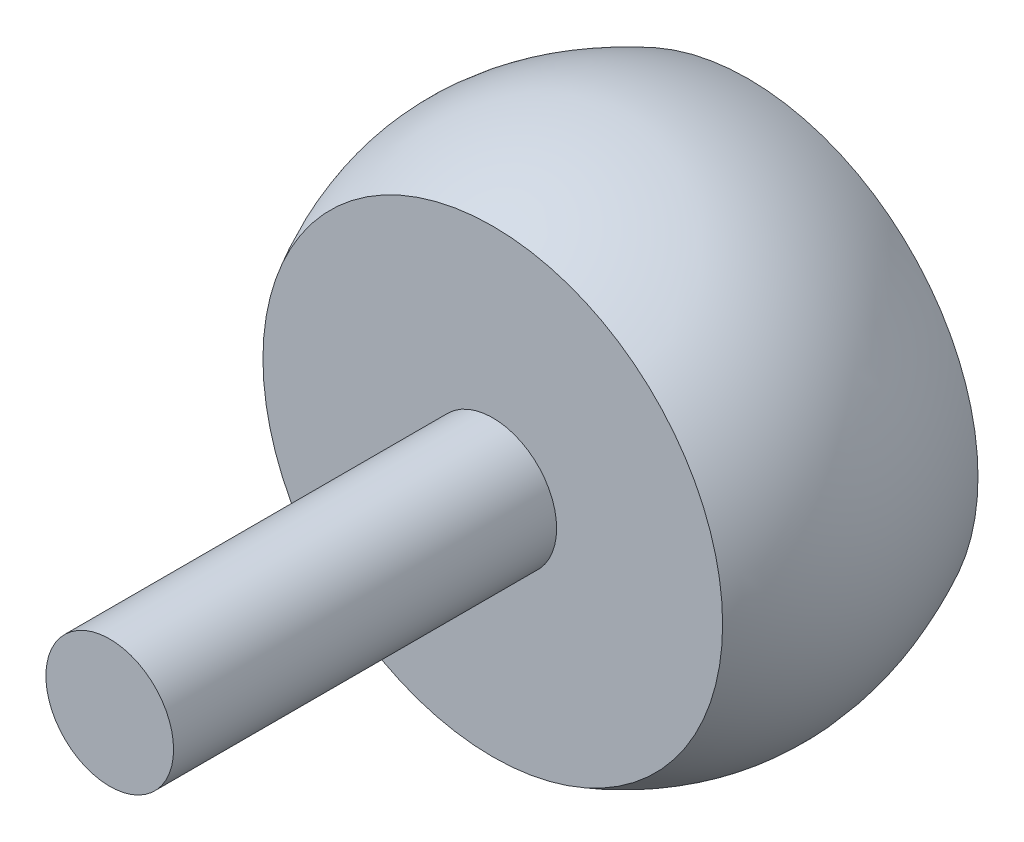
from build123d import *

# Parameters (mm, degrees)
SKETCH1_R           = 9
BOSS_EXTRUDE1_DEPTH = 10
SKETCH3_R           = 2.5
BOSS_EXTRUDE2_DEPTH = 15


with BuildPart() as part:
    # Sketch1 → Boss-Extrude1 (new body)
    with BuildSketch(Plane.XY):
        Circle(SKETCH1_R)
    extrude(amount=BOSS_EXTRUDE1_DEPTH)

    # Sketch2 → Revolve1 (revolve)
    with BuildSketch(Plane(origin=(0, 0, 0), x_dir=(0, 0, -1), z_dir=(1, 0, 0))):
        with BuildLine():
            Line((-10, 9), (0, 9))
            add(Edge.make_bspline(
                [(-10, 9), (-7.025299732, 10.664982645), (-3.75093179, 10.87766674), (0, 9)],
                knots=[0, 0, 0, 0, 1, 1, 1, 1], degree=3))
        make_face()
    revolve(axis=Axis((0, 0, 17.888498858), (0, 0, -1)))

    # Sketch3 → Boss-Extrude2 (add)
    with BuildSketch(Plane.XY.offset(10)):
        Circle(SKETCH3_R)
    extrude(amount=BOSS_EXTRUDE2_DEPTH)


solid = part.part
